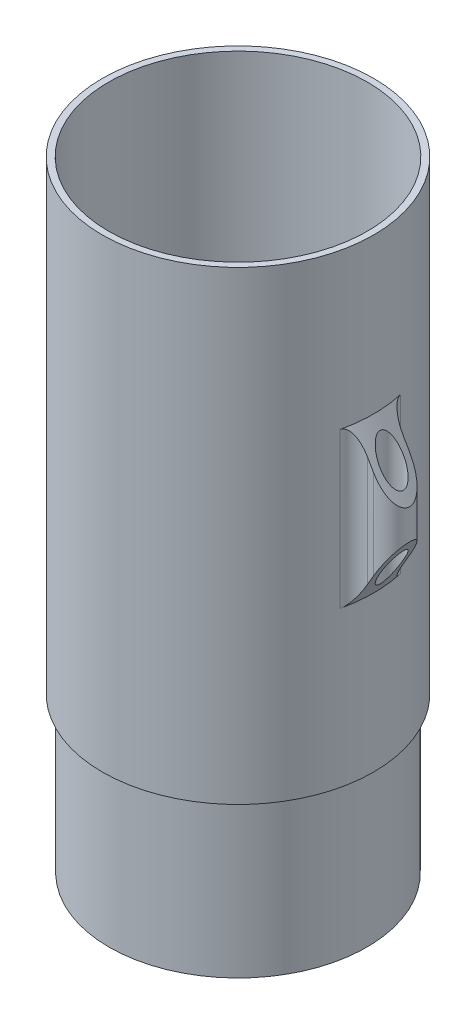
from build123d import *

# Parameters (mm, degrees)
BOSS_EXTRUDE1_START = -25.4
SKETCH2_R           = 1.905
BOSS_EXTRUDE1_DEPTH = 25.4
FILLET1_R           = 2.54


with BuildPart() as part:
    # Sketch1 → Revolve1 (revolve)
    with BuildSketch(Plane.XY):
        Polygon((-20.0787, -6.858779284), (-20.0787, 20.444981856), (-21.1836, 24.568524793), (-21.1836, 94.741220716), (-22.225, 94.741220716), (-22.225, 18.541220716), (-21.1201, 18.541220716), (-21.1201, -6.858779284), align=None)
    revolve(axis=Axis((0, 0, 0), (0, 1, 0)))

    # Sketch2 → Boss-Extrude1 (add)
    with BuildSketch(Plane(origin=(0, 94.741220716, 0), x_dir=(1, 0, 0), z_dir=(0, 1, 0)).offset(BOSS_EXTRUDE1_START)):
        with BuildLine():
            Line((25.1714, 2.9464), (22.02883002, 2.9464))
            ThreePointArc((22.02883002, 2.9464), (22.225, 0), (22.02883002, -2.9464))
            Line((22.02883002, -2.9464), (25.1714, -2.9464))
            ThreePointArc((25.1714, -2.9464), (28.1178, 0), (25.1714, 2.9464))
        make_face()
        with Locations((25.1714, 0)):
            Circle(SKETCH2_R, mode=Mode.SUBTRACT)
    extrude(amount=-BOSS_EXTRUDE1_DEPTH)

    # Fillet1
    fillet1_edges = [part.edges().sort_by_distance(p)[0] for p in [
        (22.02883002, 56.641220716, 2.9464),
        (22.02883002, 56.641220716, -2.9464),
    ]]
    fillet(fillet1_edges, radius=FILLET1_R)

    # Sketch3 → Cut-Revolve2 (revolve, cut)
    with BuildSketch(Plane.XY):
        Polygon((22.225, 69.341220716), (28.1178, 59.134591717), (28.1178, 69.341220716), align=None)
        Polygon((22.225, 43.941220716), (28.1178, 54.147849715), (28.1178, 43.941220716), align=None)
    revolve(axis=Axis((0, 0, 0), (0, -1, 0)), mode=Mode.SUBTRACT)


solid = part.part
